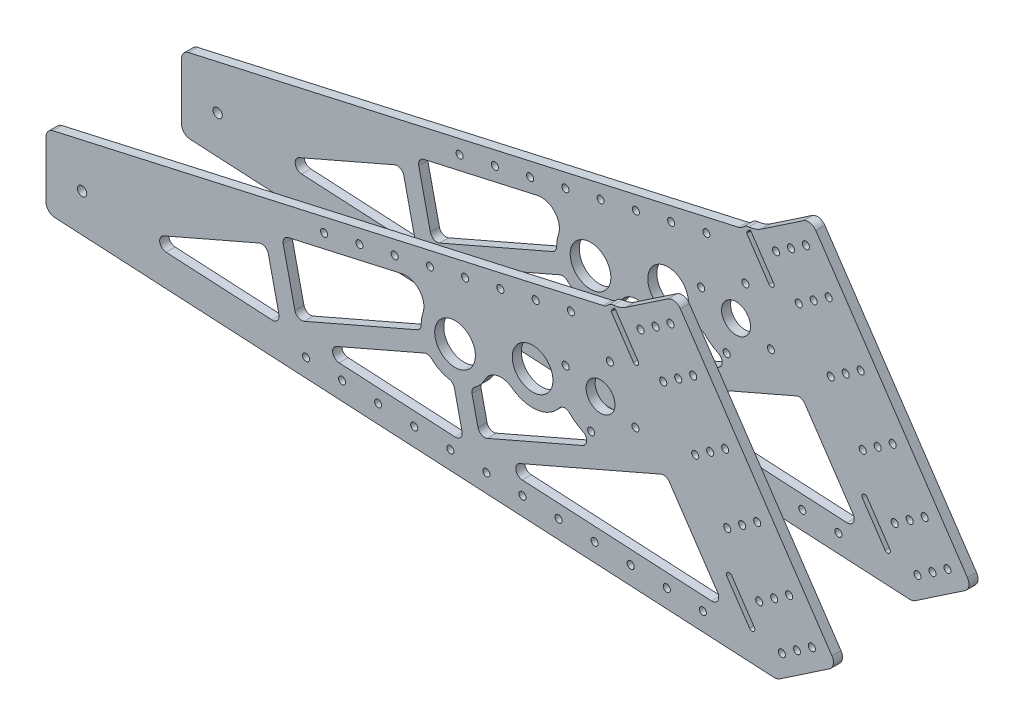
from build123d import *

# Parameters (mm, degrees)
BEARING_BLOCK_INTERFACE_PLATE_R = 2.4892
BOSS_EXTRUDE1_DEPTH             = 6.35
FILLET2_R                       = 6.35
PLATE_GB_R                      = 2.4892
PLATE_GB_R_2                    = 14.2875
PLATE_GB_R_3                    = 10.16
BOSS_EXTRUDE2_DEPTH             = 6.35
FILLET1_R                       = 6.35
CUT_EXTRUDE1_REACH              = 8.35
TUBE_R                          = 2.4892
TUBE_R_2                        = 3.2639
CUT_EXTRUDE2_REACH              = 8.35
FILLET3_R                       = 4.7625
FILLET4_R                       = 0.635


with BuildPart() as part:
    # bearing block interface plate → Boss-Extrude1 (new body)
    with BuildSketch(Plane.XY.offset(50.8)):
        Polygon((529.051438, 336.148395), (571.166546, 364.555394), (684.794544, 196.094959), (642.679436, 167.68796), align=None)
        with Locations((646.106463, 185.318487)):
            Circle(BEARING_BLOCK_INTERFACE_PLATE_R, mode=Mode.SUBTRACT)
        with Locations((656.63524, 192.420237)):
            Circle(BEARING_BLOCK_INTERFACE_PLATE_R, mode=Mode.SUBTRACT)
        with Locations((667.164017, 199.521987)):
            Circle(BEARING_BLOCK_INTERFACE_PLATE_R, mode=Mode.SUBTRACT)
        with Locations((567.739519, 346.924867)):
            Circle(BEARING_BLOCK_INTERFACE_PLATE_R, mode=Mode.SUBTRACT)
        with Locations((557.210742, 339.823117)):
            Circle(BEARING_BLOCK_INTERFACE_PLATE_R, mode=Mode.SUBTRACT)
        with Locations((546.681965, 332.721367)):
            Circle(BEARING_BLOCK_INTERFACE_PLATE_R, mode=Mode.SUBTRACT)
        with Locations((562.660902, 309.031619)):
            Circle(BEARING_BLOCK_INTERFACE_PLATE_R, mode=Mode.SUBTRACT)
        with Locations((573.189679, 316.133369)):
            Circle(BEARING_BLOCK_INTERFACE_PLATE_R, mode=Mode.SUBTRACT)
        with Locations((583.718456, 323.235118)):
            Circle(BEARING_BLOCK_INTERFACE_PLATE_R, mode=Mode.SUBTRACT)
        with Locations((606.207331, 289.893991)):
            Circle(BEARING_BLOCK_INTERFACE_PLATE_R, mode=Mode.SUBTRACT)
        with Locations((595.678554, 282.792241)):
            Circle(BEARING_BLOCK_INTERFACE_PLATE_R, mode=Mode.SUBTRACT)
        with Locations((585.149777, 275.690491)):
            Circle(BEARING_BLOCK_INTERFACE_PLATE_R, mode=Mode.SUBTRACT)
        with Locations((628.696206, 256.552863)):
            Circle(BEARING_BLOCK_INTERFACE_PLATE_R, mode=Mode.SUBTRACT)
        with Locations((618.167428, 249.451113)):
            Circle(BEARING_BLOCK_INTERFACE_PLATE_R, mode=Mode.SUBTRACT)
        with Locations((607.638651, 242.349363)):
            Circle(BEARING_BLOCK_INTERFACE_PLATE_R, mode=Mode.SUBTRACT)
        with Locations((651.18508, 223.211735)):
            Circle(BEARING_BLOCK_INTERFACE_PLATE_R, mode=Mode.SUBTRACT)
        with Locations((640.656303, 216.109985)):
            Circle(BEARING_BLOCK_INTERFACE_PLATE_R, mode=Mode.SUBTRACT)
        with Locations((630.127526, 209.008236)):
            Circle(BEARING_BLOCK_INTERFACE_PLATE_R, mode=Mode.SUBTRACT)
    extrude(amount=-BOSS_EXTRUDE1_DEPTH)

    # Fillet2
    fillet2_edges = [part.edges().sort_by_distance(p)[0] for p in [
        (529.051438, 336.148395, 47.625),
        (571.166546, 364.555394, 47.625),
        (684.794544, 196.094959, 47.625),
        (642.679436, 167.68796, 47.625),
    ]]
    fillet(fillet2_edges, radius=FILLET2_R)

    # plate+gb → Boss-Extrude2 (add)
    with BuildSketch(Plane.XY.offset(50.8)):
        with BuildLine():
            Line((128.737342, 246.126), (128.737342, 195.326))
            Line((128.737342, 195.326), (642.679436, 167.68796))
            Line((642.679436, 167.68796), (684.794544, 196.094959))
            Line((684.794544, 196.094959), (571.166546, 364.555394))
            Line((571.166546, 364.555394), (536.539349, 341.199055))
            ThreePointArc((536.539349, 341.199055), (532.275534, 339.045477), (527.610013, 338.020326))
            ThreePointArc((527.610013, 338.020326), (524.749478, 337.001009), (522.735639, 334.728102))
            Line((522.735639, 334.728102), (128.737342, 246.126))
        make_face()
        with BuildLine():
            Line((529.051438, 336.148395), (545.030375, 312.458646))
            ThreePointArc((545.030375, 312.458646), (544.490686, 309.682185), (541.714225, 310.221874))
            Line((541.714225, 310.221874), (525.976366, 333.55421))
            ThreePointArc((525.976366, 333.55421), (526.997536, 335.313412), (528.47312, 336.713494))
            ThreePointArc((528.47312, 336.713494), (528.791135, 336.460475), (529.051438, 336.148395))
        make_face(mode=Mode.SUBTRACT)
        with Locations((646.106463, 185.318487)):
            Circle(PLATE_GB_R, mode=Mode.SUBTRACT)
        with BuildLine():
            ThreePointArc((607.405411, 212.830686), (607.9451, 215.607147), (610.721561, 215.067457))
            Line((610.721561, 215.067457), (626.700499, 191.377709))
            ThreePointArc((626.700499, 191.377709), (626.160809, 188.601248), (623.384348, 189.140937))
            Line((623.384348, 189.140937), (607.405411, 212.830686))
        make_face(mode=Mode.SUBTRACT)
        with Locations((656.63524, 192.420237)):
            Circle(PLATE_GB_R, mode=Mode.SUBTRACT)
        with Locations((667.164017, 199.521987)):
            Circle(PLATE_GB_R, mode=Mode.SUBTRACT)
        with Locations((630.127526, 209.008236)):
            Circle(PLATE_GB_R, mode=Mode.SUBTRACT)
        with Locations((640.656303, 216.109985)):
            Circle(PLATE_GB_R, mode=Mode.SUBTRACT)
        with Locations((416.286581, 258.721245)):
            Circle(PLATE_GB_R_2, mode=Mode.SUBTRACT)
        with Locations((511.996015, 253.341484)):
            Circle(PLATE_GB_R, mode=Mode.SUBTRACT)
        with Locations((651.18508, 223.211735)):
            Circle(PLATE_GB_R, mode=Mode.SUBTRACT)
        with Locations((607.638651, 242.349363)):
            Circle(PLATE_GB_R, mode=Mode.SUBTRACT)
        with Locations((618.167428, 249.451113)):
            Circle(PLATE_GB_R, mode=Mode.SUBTRACT)
        with Locations((628.696206, 256.552863)):
            Circle(PLATE_GB_R, mode=Mode.SUBTRACT)
        with Locations((470.805062, 270.981329)):
            Circle(PLATE_GB_R_2, mode=Mode.SUBTRACT)
        with Locations((543.104534, 271.301996)):
            Circle(PLATE_GB_R, mode=Mode.SUBTRACT)
        with Locations((518.570018, 277.876)):
            Circle(PLATE_GB_R_3, mode=Mode.SUBTRACT)
        with Locations((494.035502, 284.450004)):
            Circle(PLATE_GB_R, mode=Mode.SUBTRACT)
        with Locations((525.144022, 302.410516)):
            Circle(PLATE_GB_R, mode=Mode.SUBTRACT)
        with Locations((585.149777, 275.690491)):
            Circle(PLATE_GB_R, mode=Mode.SUBTRACT)
        with Locations((595.678554, 282.792241)):
            Circle(PLATE_GB_R, mode=Mode.SUBTRACT)
        with Locations((606.207331, 289.893991)):
            Circle(PLATE_GB_R, mode=Mode.SUBTRACT)
        with Locations((562.660902, 309.031619)):
            Circle(PLATE_GB_R, mode=Mode.SUBTRACT)
        with Locations((573.189679, 316.133369)):
            Circle(PLATE_GB_R, mode=Mode.SUBTRACT)
        with Locations((583.718456, 323.235118)):
            Circle(PLATE_GB_R, mode=Mode.SUBTRACT)
        with Locations((546.681965, 332.721367)):
            Circle(PLATE_GB_R, mode=Mode.SUBTRACT)
        with Locations((557.210742, 339.823117)):
            Circle(PLATE_GB_R, mode=Mode.SUBTRACT)
        with Locations((567.739519, 346.924867)):
            Circle(PLATE_GB_R, mode=Mode.SUBTRACT)
    extrude(amount=-BOSS_EXTRUDE2_DEPTH)

    # Fillet1
    fillet1_edges = [part.edges().sort_by_distance(p)[0] for p in [
        (571.166546, 364.555394, 47.625),
        (684.794544, 196.094959, 47.625),
        (642.679436, 167.68796, 47.625),
        (128.737342, 195.326, 47.625),
        (128.737342, 246.126, 47.625),
        (522.735639, 334.728102, 47.625),
    ]]
    fillet(fillet1_edges, radius=FILLET1_R)

    # tube → Cut-Extrude1 (cut, up to next)
    with BuildSketch(Plane.XY.offset(50.8), mode=Mode.PRIVATE) as cut_extrude1_sk1:
        with Locations((497.728501, 319.341638)):
            Circle(TUBE_R)
    cut_extrude1_tool1 = extrude(cut_extrude1_sk1.sketch, amount=-CUT_EXTRUDE1_REACH, mode=Mode.PRIVATE) & part.part
    add(cut_extrude1_tool1.solids().sort_by_distance((497.728501, 319.341638, 50.8))[0], mode=Mode.SUBTRACT)
    # tube → Cut-Extrude1 (cut, up to next)
    with BuildSketch(Plane.XY.offset(50.8), mode=Mode.PRIVATE) as cut_extrude1_sk2:
        with Locations((472.947373, 313.768873)):
            Circle(TUBE_R)
    cut_extrude1_tool2 = extrude(cut_extrude1_sk2.sketch, amount=-CUT_EXTRUDE1_REACH, mode=Mode.PRIVATE) & part.part
    add(cut_extrude1_tool2.solids().sort_by_distance((472.947373, 313.768873, 50.8))[0], mode=Mode.SUBTRACT)
    # tube → Cut-Extrude1 (cut, up to next)
    with BuildSketch(Plane.XY.offset(50.8), mode=Mode.PRIVATE) as cut_extrude1_sk3:
        with Locations((448.166246, 308.196108)):
            Circle(TUBE_R)
    cut_extrude1_tool3 = extrude(cut_extrude1_sk3.sketch, amount=-CUT_EXTRUDE1_REACH, mode=Mode.PRIVATE) & part.part
    add(cut_extrude1_tool3.solids().sort_by_distance((448.166246, 308.196108, 50.8))[0], mode=Mode.SUBTRACT)
    # tube → Cut-Extrude1 (cut, up to next)
    with BuildSketch(Plane.XY.offset(50.8), mode=Mode.PRIVATE) as cut_extrude1_sk4:
        with Locations((423.385118, 302.623343)):
            Circle(TUBE_R)
    cut_extrude1_tool4 = extrude(cut_extrude1_sk4.sketch, amount=-CUT_EXTRUDE1_REACH, mode=Mode.PRIVATE) & part.part
    add(cut_extrude1_tool4.solids().sort_by_distance((423.385118, 302.623343, 50.8))[0], mode=Mode.SUBTRACT)
    # tube → Cut-Extrude1 (cut, up to next)
    with BuildSketch(Plane.XY.offset(50.8), mode=Mode.PRIVATE) as cut_extrude1_sk5:
        with Locations((398.60399, 297.050578)):
            Circle(TUBE_R)
    cut_extrude1_tool5 = extrude(cut_extrude1_sk5.sketch, amount=-CUT_EXTRUDE1_REACH, mode=Mode.PRIVATE) & part.part
    add(cut_extrude1_tool5.solids().sort_by_distance((398.60399, 297.050578, 50.8))[0], mode=Mode.SUBTRACT)
    # tube → Cut-Extrude1 (cut, up to next)
    with BuildSketch(Plane.XY.offset(50.8), mode=Mode.PRIVATE) as cut_extrude1_sk6:
        with Locations((373.822863, 291.477813)):
            Circle(TUBE_R)
    cut_extrude1_tool6 = extrude(cut_extrude1_sk6.sketch, amount=-CUT_EXTRUDE1_REACH, mode=Mode.PRIVATE) & part.part
    add(cut_extrude1_tool6.solids().sort_by_distance((373.822863, 291.477813, 50.8))[0], mode=Mode.SUBTRACT)
    # tube → Cut-Extrude1 (cut, up to next)
    with BuildSketch(Plane.XY.offset(50.8), mode=Mode.PRIVATE) as cut_extrude1_sk7:
        with Locations((590.508281, 183.211896)):
            Circle(TUBE_R)
    cut_extrude1_tool7 = extrude(cut_extrude1_sk7.sketch, amount=-CUT_EXTRUDE1_REACH, mode=Mode.PRIVATE) & part.part
    add(cut_extrude1_tool7.solids().sort_by_distance((590.508281, 183.211896, 50.8))[0], mode=Mode.SUBTRACT)
    # tube → Cut-Extrude1 (cut, up to next)
    with BuildSketch(Plane.XY.offset(50.8), mode=Mode.PRIVATE) as cut_extrude1_sk8:
        with Locations((565.144929, 184.57585)):
            Circle(TUBE_R)
    cut_extrude1_tool8 = extrude(cut_extrude1_sk8.sketch, amount=-CUT_EXTRUDE1_REACH, mode=Mode.PRIVATE) & part.part
    add(cut_extrude1_tool8.solids().sort_by_distance((565.144929, 184.57585, 50.8))[0], mode=Mode.SUBTRACT)
    # tube → Cut-Extrude1 (cut, up to next)
    with BuildSketch(Plane.XY.offset(50.8), mode=Mode.PRIVATE) as cut_extrude1_sk9:
        with Locations((539.781577, 185.939804)):
            Circle(TUBE_R)
    cut_extrude1_tool9 = extrude(cut_extrude1_sk9.sketch, amount=-CUT_EXTRUDE1_REACH, mode=Mode.PRIVATE) & part.part
    add(cut_extrude1_tool9.solids().sort_by_distance((539.781577, 185.939804, 50.8))[0], mode=Mode.SUBTRACT)
    # tube → Cut-Extrude1 (cut, up to next)
    with BuildSketch(Plane.XY.offset(50.8), mode=Mode.PRIVATE) as cut_extrude1_sk10:
        with Locations((514.418225, 187.303758)):
            Circle(TUBE_R)
    cut_extrude1_tool10 = extrude(cut_extrude1_sk10.sketch, amount=-CUT_EXTRUDE1_REACH, mode=Mode.PRIVATE) & part.part
    add(cut_extrude1_tool10.solids().sort_by_distance((514.418225, 187.303758, 50.8))[0], mode=Mode.SUBTRACT)
    # tube → Cut-Extrude1 (cut, up to next)
    with BuildSketch(Plane.XY.offset(50.8), mode=Mode.PRIVATE) as cut_extrude1_sk11:
        with Locations((489.054872, 188.667712)):
            Circle(TUBE_R)
    cut_extrude1_tool11 = extrude(cut_extrude1_sk11.sketch, amount=-CUT_EXTRUDE1_REACH, mode=Mode.PRIVATE) & part.part
    add(cut_extrude1_tool11.solids().sort_by_distance((489.054872, 188.667712, 50.8))[0], mode=Mode.SUBTRACT)
    # tube → Cut-Extrude1 (cut, up to next)
    with BuildSketch(Plane.XY.offset(50.8), mode=Mode.PRIVATE) as cut_extrude1_sk12:
        with Locations((463.69152, 190.031666)):
            Circle(TUBE_R)
    cut_extrude1_tool12 = extrude(cut_extrude1_sk12.sketch, amount=-CUT_EXTRUDE1_REACH, mode=Mode.PRIVATE) & part.part
    add(cut_extrude1_tool12.solids().sort_by_distance((463.69152, 190.031666, 50.8))[0], mode=Mode.SUBTRACT)
    # tube → Cut-Extrude1 (cut, up to next)
    with BuildSketch(Plane.XY.offset(50.8), mode=Mode.PRIVATE) as cut_extrude1_sk13:
        with Locations((438.328168, 191.395619)):
            Circle(TUBE_R)
    cut_extrude1_tool13 = extrude(cut_extrude1_sk13.sketch, amount=-CUT_EXTRUDE1_REACH, mode=Mode.PRIVATE) & part.part
    add(cut_extrude1_tool13.solids().sort_by_distance((438.328168, 191.395619, 50.8))[0], mode=Mode.SUBTRACT)
    # tube → Cut-Extrude1 (cut, up to next)
    with BuildSketch(Plane.XY.offset(50.8), mode=Mode.PRIVATE) as cut_extrude1_sk14:
        with Locations((412.964816, 192.759573)):
            Circle(TUBE_R)
    cut_extrude1_tool14 = extrude(cut_extrude1_sk14.sketch, amount=-CUT_EXTRUDE1_REACH, mode=Mode.PRIVATE) & part.part
    add(cut_extrude1_tool14.solids().sort_by_distance((412.964816, 192.759573, 50.8))[0], mode=Mode.SUBTRACT)
    # tube → Cut-Extrude1 (cut, up to next)
    with BuildSketch(Plane.XY.offset(50.8), mode=Mode.PRIVATE) as cut_extrude1_sk15:
        with Locations((387.601464, 194.123527)):
            Circle(TUBE_R)
    cut_extrude1_tool15 = extrude(cut_extrude1_sk15.sketch, amount=-CUT_EXTRUDE1_REACH, mode=Mode.PRIVATE) & part.part
    add(cut_extrude1_tool15.solids().sort_by_distance((387.601464, 194.123527, 50.8))[0], mode=Mode.SUBTRACT)
    # tube → Cut-Extrude1 (cut, up to next)
    with BuildSketch(Plane.XY.offset(50.8), mode=Mode.PRIVATE) as cut_extrude1_sk16:
        with Locations((362.238112, 195.487481)):
            Circle(TUBE_R)
    cut_extrude1_tool16 = extrude(cut_extrude1_sk16.sketch, amount=-CUT_EXTRUDE1_REACH, mode=Mode.PRIVATE) & part.part
    add(cut_extrude1_tool16.solids().sort_by_distance((362.238112, 195.487481, 50.8))[0], mode=Mode.SUBTRACT)
    # tube → Cut-Extrude1 (cut, up to next)
    with BuildSketch(Plane.XY.offset(50.8), mode=Mode.PRIVATE) as cut_extrude1_sk17:
        with Locations((336.87476, 196.851435)):
            Circle(TUBE_R)
    cut_extrude1_tool17 = extrude(cut_extrude1_sk17.sketch, amount=-CUT_EXTRUDE1_REACH, mode=Mode.PRIVATE) & part.part
    add(cut_extrude1_tool17.solids().sort_by_distance((336.87476, 196.851435, 50.8))[0], mode=Mode.SUBTRACT)
    # tube → Cut-Extrude1 (cut, up to next)
    with BuildSketch(Plane.XY.offset(50.8), mode=Mode.PRIVATE) as cut_extrude1_sk18:
        with Locations((311.511408, 198.215389)):
            Circle(TUBE_R)
    cut_extrude1_tool18 = extrude(cut_extrude1_sk18.sketch, amount=-CUT_EXTRUDE1_REACH, mode=Mode.PRIVATE) & part.part
    add(cut_extrude1_tool18.solids().sort_by_distance((311.511408, 198.215389, 50.8))[0], mode=Mode.SUBTRACT)
    # tube → Cut-Extrude1 (cut, up to next)
    with BuildSketch(Plane.XY.offset(50.8), mode=Mode.PRIVATE) as cut_extrude1_sk19:
        with Locations((349.041735, 285.905047)):
            Circle(TUBE_R)
    cut_extrude1_tool19 = extrude(cut_extrude1_sk19.sketch, amount=-CUT_EXTRUDE1_REACH, mode=Mode.PRIVATE) & part.part
    add(cut_extrude1_tool19.solids().sort_by_distance((349.041735, 285.905047, 50.8))[0], mode=Mode.SUBTRACT)
    # tube → Cut-Extrude1 (cut, up to next)
    with BuildSketch(Plane.XY.offset(50.8), mode=Mode.PRIVATE) as cut_extrude1_sk20:
        with Locations((324.260607, 280.332282)):
            Circle(TUBE_R)
    cut_extrude1_tool20 = extrude(cut_extrude1_sk20.sketch, amount=-CUT_EXTRUDE1_REACH, mode=Mode.PRIVATE) & part.part
    add(cut_extrude1_tool20.solids().sort_by_distance((324.260607, 280.332282, 50.8))[0], mode=Mode.SUBTRACT)
    # tube → Cut-Extrude1 (cut, up to next)
    with BuildSketch(Plane.XY.offset(50.8), mode=Mode.PRIVATE) as cut_extrude1_sk21:
        with Locations((154.137342, 220.726)):
            Circle(TUBE_R_2)
    cut_extrude1_tool21 = extrude(cut_extrude1_sk21.sketch, amount=-CUT_EXTRUDE1_REACH, mode=Mode.PRIVATE) & part.part
    add(cut_extrude1_tool21.solids().sort_by_distance((154.137342, 220.726, 50.8))[0], mode=Mode.SUBTRACT)

    # Sketch20 → Cut-Extrude2 (cut, up to next)
    with BuildSketch(Plane.XY.offset(50.8), mode=Mode.PRIVATE) as cut_extrude2_sk1:
        Polygon((283.778218, 253.593942), (193.02712, 214.12583), (293.873342, 208.702667), align=None)
    cut_extrude2_tool1 = extrude(cut_extrude2_sk1.sketch, amount=-CUT_EXTRUDE2_REACH, mode=Mode.PRIVATE) & part.part
    add(cut_extrude2_tool1.solids().sort_by_distance((256.892893, 225.474146, 50.8))[0], mode=Mode.SUBTRACT)
    # Sketch20 → Cut-Extrude2 (cut, up to next)
    with BuildSketch(Plane.XY.offset(50.8), mode=Mode.PRIVATE) as cut_extrude2_sk2:
        with BuildLine():
            Line((304.971882, 217.234454), (392.708052, 255.39136))
            ThreePointArc((392.708052, 255.39136), (392.578527, 260.949108), (393.741172, 266.38543))
            ThreePointArc((393.741172, 266.38543), (391.162407, 278.962601), (378.930572, 282.863558))
            Line((378.930572, 282.863558), (294.483785, 263.873215))
            Line((294.483785, 263.873215), (304.971882, 217.234454))
        make_face()
    cut_extrude2_tool2 = extrude(cut_extrude2_sk2.sketch, amount=-CUT_EXTRUDE2_REACH, mode=Mode.PRIVATE) & part.part
    add(cut_extrude2_tool2.solids().sort_by_distance((342.159835, 254.458367, 50.8))[0], mode=Mode.SUBTRACT)
    # Sketch20 → Cut-Extrude2 (cut, up to next)
    with BuildSketch(Plane.XY.offset(50.8), mode=Mode.PRIVATE) as cut_extrude2_sk3:
        with BuildLine():
            Line((397.773073, 243.745091), (314.631427, 207.586368))
            Line((314.631427, 207.586368), (422.58266, 201.781122))
            Line((422.58266, 201.781122), (415.126582, 234.937016))
            ThreePointArc((415.126582, 234.937016), (405.508953, 237.48736), (397.773073, 243.745091))
        make_face()
    cut_extrude2_tool3 = extrude(cut_extrude2_sk3.sketch, amount=-CUT_EXTRUDE2_REACH, mode=Mode.PRIVATE) & part.part
    add(cut_extrude2_tool3.solids().sort_by_distance((381.543889, 218.429138, 50.8))[0], mode=Mode.SUBTRACT)
    # Sketch20 → Cut-Extrude2 (cut, up to next)
    with BuildSketch(Plane.XY.offset(50.8), mode=Mode.PRIVATE) as cut_extrude2_sk4:
        with BuildLine():
            ThreePointArc((437.427712, 247.762791), (433.232938, 241.992344), (427.517146, 237.723399))
            Line((427.517146, 237.723399), (433.6812, 210.31291))
            Line((433.6812, 210.31291), (519.729608, 247.735798))
            ThreePointArc((519.729608, 247.735798), (504.36793, 251.266282), (492.884616, 262.063457))
            ThreePointArc((492.884616, 262.063457), (477.119365, 248.021261), (456.390662, 252.027167))
            ThreePointArc((456.390662, 252.027167), (445.916599, 254.308845), (437.427712, 247.762791))
        make_face()
    cut_extrude2_tool4 = extrude(cut_extrude2_sk4.sketch, amount=-CUT_EXTRUDE2_REACH, mode=Mode.PRIVATE) & part.part
    add(cut_extrude2_tool4.solids().sort_by_distance((463.243993, 237.371256, 50.8))[0], mode=Mode.SUBTRACT)
    # Sketch20 → Cut-Extrude2 (cut, up to next)
    with BuildSketch(Plane.XY.offset(50.8), mode=Mode.PRIVATE) as cut_extrude2_sk5:
        Polygon((564.693835, 253.441897), (443.340745, 200.664823), (606.199766, 191.906825), align=None)
    cut_extrude2_tool5 = extrude(cut_extrude2_sk5.sketch, amount=-CUT_EXTRUDE2_REACH, mode=Mode.PRIVATE) & part.part
    add(cut_extrude2_tool5.solids().sort_by_distance((538.078115, 215.337848, 50.8))[0], mode=Mode.SUBTRACT)

    # Fillet3
    fillet3_edges = [part.edges().sort_by_distance(p)[0] for p in [
        (293.873342, 208.702667, 47.625),
        (193.02712, 214.12583, 47.625),
        (283.778218, 253.593942, 47.625),
        (397.773073, 243.745091, 47.625),
        (415.126582, 234.937016, 47.625),
        (422.58266, 201.781122, 47.625),
        (314.631427, 207.586368, 47.625),
        (392.708052, 255.39136, 47.625),
        (304.971882, 217.234454, 47.625),
        (294.483785, 263.873215, 47.625),
        (443.340745, 200.664823, 47.625),
        (564.693835, 253.441897, 47.625),
        (606.199766, 191.906825, 47.625),
        (492.884616, 262.063457, 47.625),
        (519.729608, 247.735798, 47.625),
        (433.6812, 210.31291, 47.625),
        (427.517146, 237.723399, 47.625),
    ]]
    fillet(fillet3_edges, radius=FILLET3_R)

    # Fillet4
    fillet4_edges = [part.edges().sort_by_distance(p)[0] for p in [
        (528.47312, 336.713494, 47.625),
        (525.976366, 333.55421, 47.625),
    ]]
    fillet(fillet4_edges, radius=FILLET4_R)


with BuildPart() as body_2:
    # Mirror1: mirrored copy
    add(part.part.mirror(Plane.XY))


solid = Compound([part.part, body_2.part])
